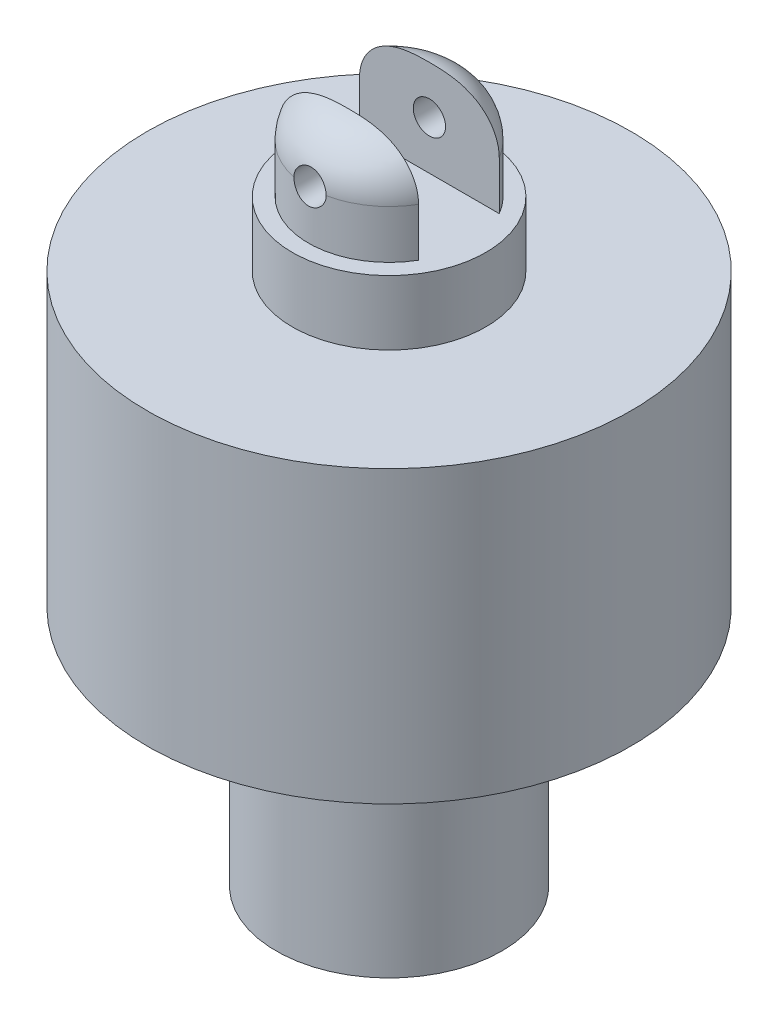
from build123d import *

# Parameters (mm, degrees)
FILLET1_R               = 3
CUT_EXTRUDE1_DEPTH      = 10
CUT_EXTRUDE1_DEPTH_BACK = 10
SKETCH3_W               = 5
SKETCH3_H               = 6
CUT_EXTRUDE2_DEPTH      = 10
CUT_EXTRUDE2_DEPTH_BACK = 10
SKETCH4_R               = 1


with BuildPart() as part:
    # Sketch2 → Revolve1 (revolve)
    with BuildSketch(Plane.XY):
        Polygon((-4, 12), (-4, 15), (-15, 15), (-15, 33), (-6, 33), (-6, 37), (-5, 37), (-5, 43), (0, 43), (0, 37), (0, 4), (-1, 4), (-1, 0), (-7, 0), (-7, 12), align=None)
    revolve(axis=Axis((0, 37, 0), (0, -1, 0)))

    # Fillet1
    fillet1_edges = [part.edges().sort_by_distance(p)[0] for p in [
        (5, 43, 0),
    ]]
    fillet(fillet1_edges, radius=FILLET1_R)

    # Sketch3 → Cut-Extrude1 (cut, two sides: drawn at the far end of the back side and taken through both)
    with BuildSketch(Plane(origin=(0, 0, 0), x_dir=(0, 0, -1), z_dir=(1, 0, 0)).offset(-CUT_EXTRUDE1_DEPTH_BACK)):
        with Locations((0, 40)):
            Rectangle(SKETCH3_W, SKETCH3_H)
    extrude(amount=CUT_EXTRUDE1_DEPTH + CUT_EXTRUDE1_DEPTH_BACK, mode=Mode.SUBTRACT)

    # Sketch4 → Cut-Extrude2 (cut, two sides: drawn at the far end of the back side and taken through both)
    with BuildSketch(Plane(origin=(0, 0, 2.5), x_dir=(-1, 0, 0), z_dir=(0, 0, -1)).offset(-CUT_EXTRUDE2_DEPTH_BACK)):
        with Locations((0, 40)):
            Circle(SKETCH4_R)
    extrude(amount=CUT_EXTRUDE2_DEPTH + CUT_EXTRUDE2_DEPTH_BACK, mode=Mode.SUBTRACT)


solid = part.part
